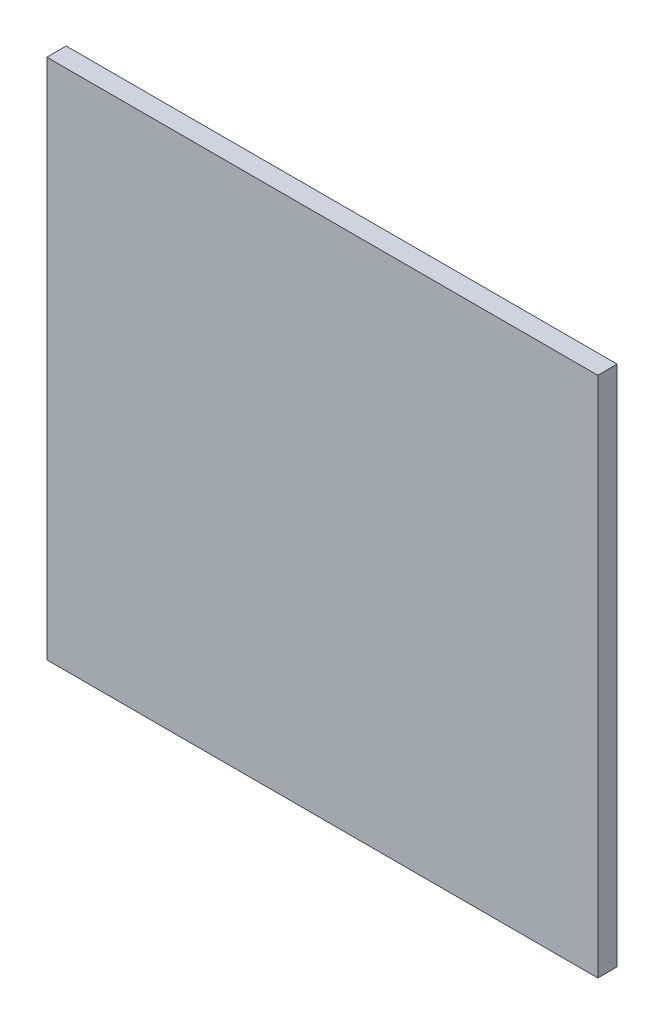
from build123d import *

# Parameters (mm, degrees)
SKETCH1_W           = 90.4875
SKETCH1_H           = 85.725
BOSS_EXTRUDE1_DEPTH = 3.175


with BuildPart() as part:
    # Sketch1 → Boss-Extrude1 (new body)
    with BuildSketch(Plane.XY):
        Rectangle(SKETCH1_W, SKETCH1_H)
    extrude(amount=BOSS_EXTRUDE1_DEPTH)


solid = part.part
